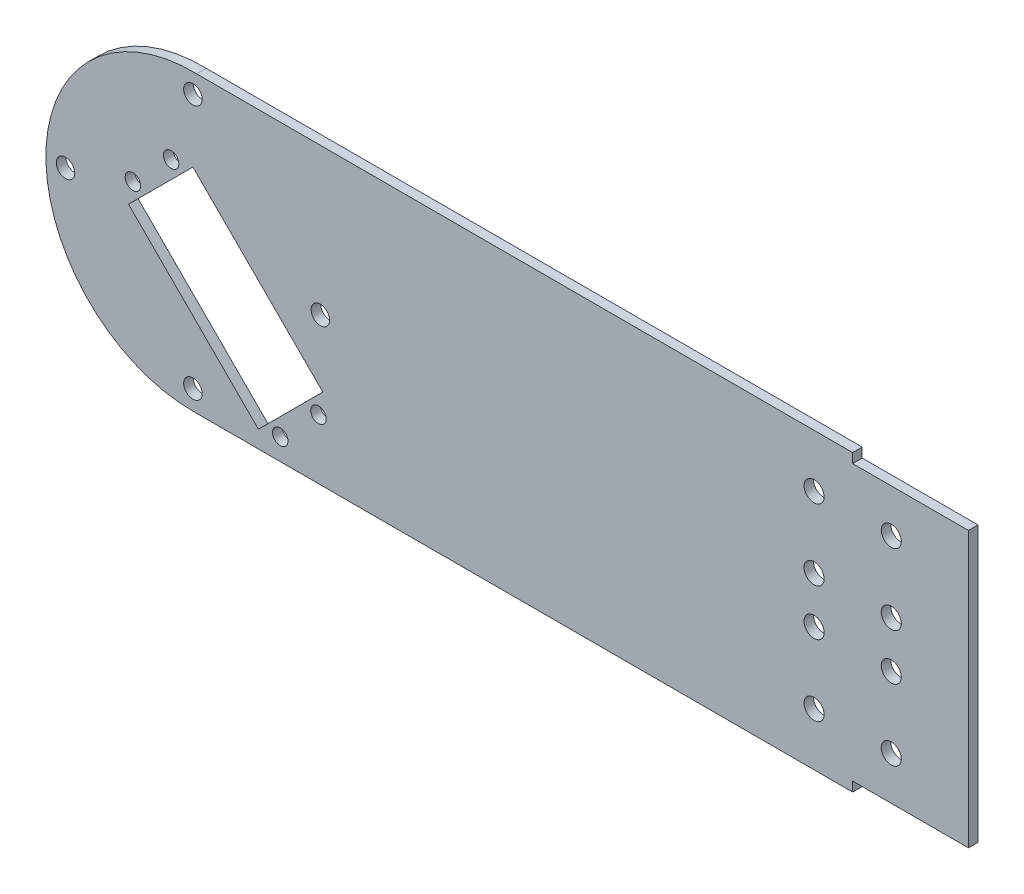
from build123d import *

# Parameters (mm, degrees)
SKETCH1_R           = 3
BOSS_EXTRUDE1_DEPTH = 3.1
SKETCH2_R           = 2.5
CUT_EXTRUDE1_DEPTH  = 4.1
SKETCH3_W           = 37.5
SKETCH3_H           = 3.1
CUT_EXTRUDE2_DEPTH  = 4.1
SKETCH7_R           = 3.25
CUT_EXTRUDE5_DEPTH  = 4.1


with BuildPart() as part:
    # Sketch1 → Boss-Extrude1 (new body)
    with BuildSketch(Plane.XY):
        with BuildLine():
            Line((0, -47.625), (251.196924141, -47.625))
            Line((251.196924141, -47.625), (251.196924141, 47.609956917))
            Line((251.196924141, 47.609956917), (1.196924141, 47.609956917))
            ThreePointArc((1.196924141, 47.609956917), (-47.621239081, 0.598509335), (0, -47.625))
        make_face()
        with Locations((0, -41.275)):
            Circle(SKETCH1_R, mode=Mode.SUBTRACT)
        with Locations((-41.275, 0)):
            Circle(SKETCH1_R, mode=Mode.SUBTRACT)
        with Locations((0, 41.275)):
            Circle(SKETCH1_R, mode=Mode.SUBTRACT)
        with Locations((41.275, 0)):
            Circle(SKETCH1_R, mode=Mode.SUBTRACT)
    extrude(amount=BOSS_EXTRUDE1_DEPTH)

    # Sketch2 → Cut-Extrude1 (cut, through all)
    with BuildSketch(Plane.XY.offset(3.1)):
        with Locations((-19.445436483, 7.071067812)):
            Circle(SKETCH2_R)
        with Locations((-7.071067812, 19.445436483)):
            Circle(SKETCH2_R)
        with Locations((40.658639918, -28.284271247)):
            Circle(SKETCH2_R)
        with Locations((28.284271247, -40.658639918)):
            Circle(SKETCH2_R)
        Polygon((21.213203436, -42.072853481), (42.072853481, -21.213203436), (0, 20.859650045), (-20.859650045, 0), align=None)
    extrude(amount=-CUT_EXTRUDE1_DEPTH, mode=Mode.SUBTRACT)

    # Sketch3 → Cut-Extrude2 (cut, through all)
    with BuildSketch(Plane.XY.offset(3.1)):
        with Locations((232.446924141, -46.075)):
            Rectangle(SKETCH3_W, SKETCH3_H)
    cut_extrude2 = extrude(amount=-CUT_EXTRUDE2_DEPTH, mode=Mode.SUBTRACT)

    # Mirror1: Cut-Extrude2 across plane
    add(cut_extrude2.mirror(Plane.ZX), mode=Mode.SUBTRACT)

    # Sketch7 → Cut-Extrude5 (cut, through all)
    with BuildSketch(Plane.XY.offset(3.1)):
        with Locations((226.196924141, -30.525)):
            Circle(SKETCH7_R)
        with Locations((226.196924141, -7.525)):
            Circle(SKETCH7_R)
        with Locations((226.196924141, 7.525)):
            Circle(SKETCH7_R)
        with Locations((226.196924141, 30.525)):
            Circle(SKETCH7_R)
        with Locations((201.196924141, -30.525)):
            Circle(SKETCH7_R)
        with Locations((201.196924141, -7.525)):
            Circle(SKETCH7_R)
        with Locations((201.196924141, 7.525)):
            Circle(SKETCH7_R)
        with Locations((201.196924141, 30.525)):
            Circle(SKETCH7_R)
    extrude(amount=-CUT_EXTRUDE5_DEPTH, mode=Mode.SUBTRACT)


solid = part.part
